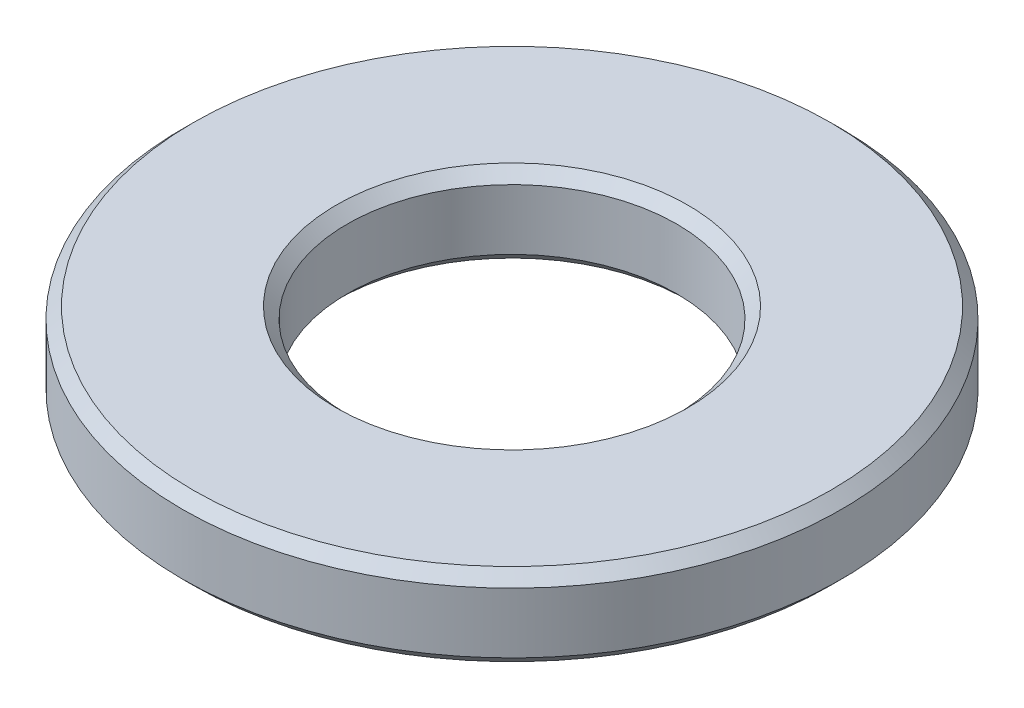
from build123d import *

# Parameters (mm, degrees)
SKETCH_1_R      = 6
SKETCH_1_R_2    = 3
EXTRUDE_1_DEPTH = 1.5
CHAMFER_1_SIZE  = 0.2


with BuildPart() as part:
    # 草图1 → 凸台-拉伸1 (new body)
    with BuildSketch(Plane(origin=(0, 0, 0), x_dir=(1, 0, 0), z_dir=(0, 1, 0))):
        Circle(SKETCH_1_R)
        Circle(SKETCH_1_R_2, mode=Mode.SUBTRACT)
    extrude(amount=EXTRUDE_1_DEPTH)

    # 倒角1
    chamfer_1_edges = [part.edges().sort_by_distance(p)[0] for p in [
        (-6, 0, 0),
        (-6, 1.5, 0),
        (-3, 0, 0),
        (-3, 1.5, 0),
    ]]
    chamfer(chamfer_1_edges, length=CHAMFER_1_SIZE)


solid = part.part
